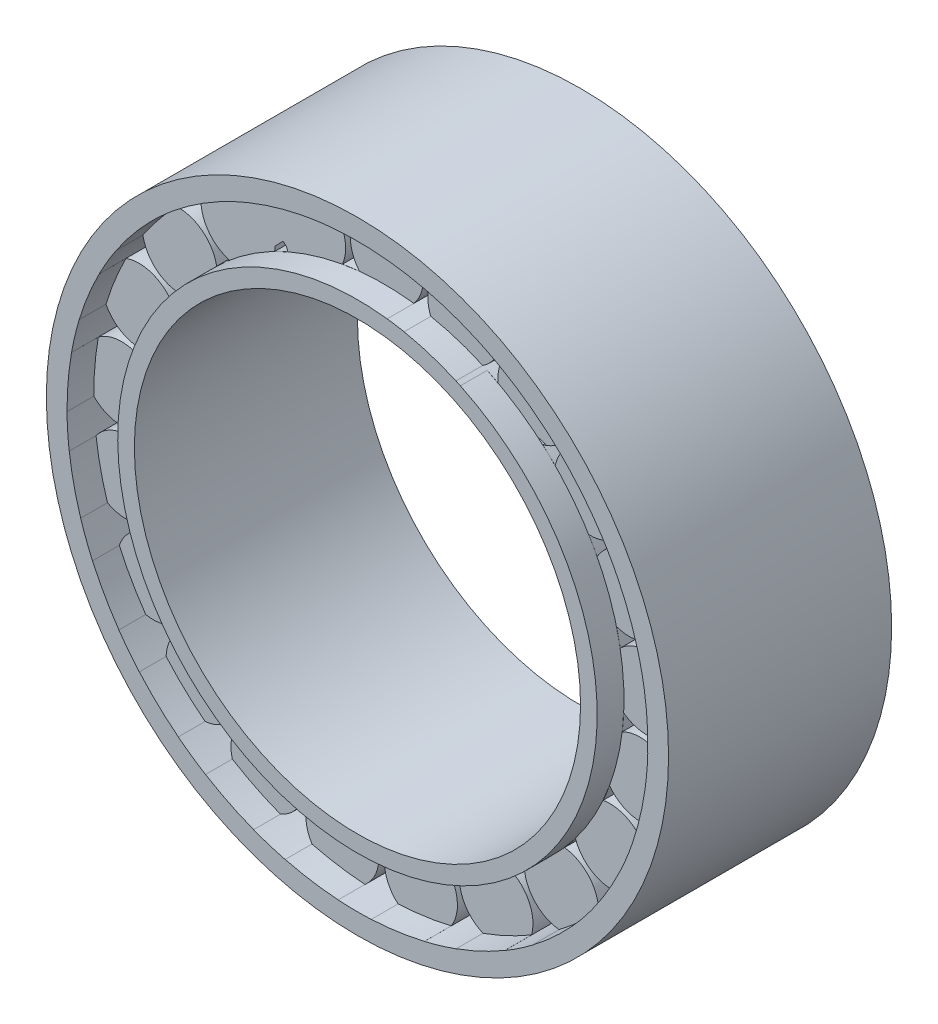
from build123d import *

# Parameters (mm, degrees)
SKETCH1_R          = 17.710128009
SKETCH1_R_2        = 12.7
BASE_EXTRUDE_DEPTH = 6.35
SKETCH2_R          = 16.531523604
SKETCH2_R_2        = 13.647455649
CUT_EXTRUDE1_DEPTH = 1.524


with BuildPart() as part:
    # Sketch1 → Base-Extrude (new body)
    with BuildSketch(Plane.XY):
        Circle(SKETCH1_R)
        Circle(SKETCH1_R_2, mode=Mode.SUBTRACT)
        with BuildLine():
            ThreePointArc((1.68979489, 13.542358951), (2.222472628, 14.997030336), (1.675382152, 16.446342732))
            ThreePointArc((1.675382152, 16.446342732), (2.615425849, 16.323254646), (3.546867553, 16.146480272))
            ThreePointArc((3.546867553, 16.146480272), (2.588094608, 14.932448412), (2.653777562, 13.386872576))
            ThreePointArc((2.653777562, 13.386872576), (2.173177263, 13.473239896), (1.68979489, 13.542358951))
        make_face(mode=Mode.SUBTRACT)
        with BuildLine():
            ThreePointArc((5.60700736, 12.442433831), (6.544791638, 13.675468729), (6.449199185, 15.22164999))
            ThreePointArc((6.449199185, 15.22164999), (7.311198528, 14.826947619), (8.149153729, 14.383479572))
            ThreePointArc((8.149153729, 14.383479572), (6.875134203, 13.505987029), (6.482332573, 12.0097164))
            ThreePointArc((6.482332573, 12.0097164), (6.048541211, 12.233906087), (5.60700736, 12.442433831))
        make_face(mode=Mode.SUBTRACT)
        with BuildLine():
            ThreePointArc((9.02598045, 10.236756654), (10.28554502, 11.138594502), (10.649944399, 12.644259638))
            ThreePointArc((10.649944399, 12.644259638), (11.357306963, 12.01301402), (12.027319665, 11.342256382))
            ThreePointArc((12.027319665, 11.342256382), (10.551255784, 10.879272218), (9.734871718, 9.565257008))
            ThreePointArc((9.734871718, 9.565257008), (9.386433559, 9.907348825), (9.02598045, 10.236756654))
        make_face(mode=Mode.SUBTRACT)
        with BuildLine():
            ThreePointArc((11.642923398, 7.121311516), (13.11235042, 7.611820064), (13.904363147, 8.94318412))
            ThreePointArc((13.904363147, 8.94318412), (14.394236664, 8.131484197), (14.836773297, 7.293036729))
            ThreePointArc((14.836773297, 7.293036729), (13.289819815, 7.285699119), (12.12239262, 6.270695346))
            ThreePointArc((12.12239262, 6.270695346), (11.890267925, 6.700292933), (11.642923398, 7.121311516))
        make_face(mode=Mode.SUBTRACT)
        with BuildLine():
            ThreePointArc((13.225309338, 3.372919389), (14.774033773, 3.4085148), (15.923286041, 4.447280237))
            ThreePointArc((15.923286041, 4.447280237), (16.1521431, 3.52724911), (16.327882343, 2.595611549))
            ThreePointArc((16.327882343, 2.595611549), (14.847492865, 3.044572471), (13.43275357, 2.418767674))
            ThreePointArc((13.43275357, 2.418767674), (13.337567635, 2.897699401), (13.225309338, 3.372919389))
        make_face(mode=Mode.SUBTRACT)
        with BuildLine():
            ThreePointArc((13.632536335, -0.675358637), (15.122947221, -1.097839171), (16.527322923, -0.44397122))
            ThreePointArc((16.527322923, -0.44397122), (16.47482857, -1.390584748), (16.368155218, -2.332632318))
            ThreePointArc((16.368155218, -2.332632318), (15.085868846, -1.467265011), (13.549523247, -1.648265329))
            ThreePointArc((13.549523247, -1.648265329), (13.599733761, -1.162554648), (13.632536335, -0.675358637))
        make_face(mode=Mode.SUBTRACT)
        with BuildLine():
            ThreePointArc((12.828420484, -4.663815293), (14.128088272, -5.506832523), (15.662802464, -5.295961096))
            ThreePointArc((15.662802464, -5.295961096), (15.333621052, -6.185046258), (14.954013503, -7.053798776))
            ThreePointArc((14.954013503, -7.053798776), (13.983767008, -5.848916767), (12.462326153, -5.569029934))
            ThreePointArc((12.462326153, -5.569029934), (12.653471691, -5.119697824), (12.828420484, -4.663815293))
        make_face(mode=Mode.SUBTRACT)
        with BuildLine():
            ThreePointArc((10.884411006, -8.238058703), (11.877854511, -9.426706849), (13.406541102, -9.677568797))
            ThreePointArc((13.406541102, -9.677568797), (12.829921844, -10.430126475), (12.211109893, -11.148391466))
            ThreePointArc((12.211109893, -11.148391466), (11.639113935, -9.71105381), (10.26776452, -8.995148999))
            ThreePointArc((10.26776452, -8.995148999), (10.582860963, -8.62212059), (10.884411006, -8.238058703))
        make_face(mode=Mode.SUBTRACT)
        with BuildLine():
            ThreePointArc((7.973241676, -11.080501654), (8.572189081, -12.509164111), (9.959017559, -13.199469249))
            ThreePointArc((9.959017559, -13.199469249), (9.186195607, -13.748631392), (8.383163412, -14.252587861))
            ThreePointArc((8.383163412, -14.252587861), (8.260242341, -12.710508315), (7.160834781, -11.62219681))
            ThreePointArc((7.160834781, -11.62219681), (7.571884426, -11.358617314), (7.973241676, -11.080501654))
        make_face(mode=Mode.SUBTRACT)
        with BuildLine():
            ThreePointArc((4.353582662, -12.938580617), (4.504814864, -14.480314456), (5.626559432, -15.548726144))
            ThreePointArc((5.626559432, -15.548726144), (4.726203408, -15.845697284), (3.810303904, -16.090566486))
            ThreePointArc((3.810303904, -16.090566486), (4.147379796, -14.580765586), (3.417601276, -13.21674864))
            ThreePointArc((3.417601276, -13.21674864), (3.88808056, -13.086038252), (4.353582662, -12.938580617))
        make_face(mode=Mode.SUBTRACT)
        with BuildLine():
            ThreePointArc((0.347056555, -13.64719712), (0.037135907, -15.165012525), (0.794124638, -16.516597695))
            ThreePointArc((0.794124638, -16.516597695), (-0.153764874, -16.534990644), (-1.101149998, -16.499014876))
            ThreePointArc((-1.101149998, -16.499014876), (-0.334027814, -15.155645057), (-0.629333269, -13.637121562))
            ThreePointArc((-0.629333269, -13.637121562), (-0.141228497, -13.650894473), (0.347056555, -13.64719712))
        make_face(mode=Mode.SUBTRACT)
        with BuildLine():
            ThreePointArc((-3.690339221, -13.143387479), (-4.433874908, -14.50241989), (-4.108903785, -16.017084268))
            ThreePointArc((-4.108903785, -16.017084268), (-5.020102642, -15.755264732), (-5.914794059, -15.441640599))
            ThreePointArc((-5.914794059, -15.441640599), (-4.785787756, -14.384066165), (-4.620380961, -12.845963597))
            ThreePointArc((-4.620380961, -12.845963597), (-4.158020951, -13.002996024), (-3.690339221, -13.143387479))
        make_face(mode=Mode.SUBTRACT)
        with BuildLine():
            ThreePointArc((-7.399864331, -11.471917391), (-8.510948649, -12.551410813), (-8.646870244, -14.094569823))
            ThreePointArc((-8.646870244, -14.094569823), (-9.44041443, -13.575801616), (-10.202914882, -13.012395999))
            ThreePointArc((-10.202914882, -13.012395999), (-8.812341624, -12.334587079), (-8.200919698, -10.913572602))
            ThreePointArc((-8.200919698, -10.913572602), (-7.805387166, -11.199911524), (-7.399864331, -11.471917391))
        make_face(mode=Mode.SUBTRACT)
        with BuildLine():
            ThreePointArc((-10.451911192, -8.781304308), (-11.831819423, -9.485341015), (-12.416556506, -10.919878206))
            ThreePointArc((-12.416556506, -10.919878206), (-13.021936137, -10.19025616), (-13.584494112, -9.42713012))
            ThreePointArc((-13.584494112, -9.42713012), (-12.055912436, -9.189313012), (-11.052802901, -8.011649997))
            ThreePointArc((-11.052802901, -8.011649997), (-10.759242648, -8.401852944), (-10.451911192, -8.781304308))
        make_face(mode=Mode.SUBTRACT)
        with BuildLine():
            ThreePointArc((-12.575292045, -5.310621011), (-14.101413288, -5.57664425), (-15.083009403, -6.775094698))
            ThreePointArc((-15.083009403, -6.775094698), (-15.446433842, -5.899448934), (-15.759063595, -5.004409569))
            ThreePointArc((-15.759063595, -5.004409569), (-14.228294691, -5.227715366), (-12.922628231, -4.398044341))
            ThreePointArc((-12.922628231, -4.398044341), (-12.757124375, -4.857440069), (-12.575292045, -5.310621011))
        make_face(mode=Mode.SUBTRACT)
        with BuildLine():
            ThreePointArc((-13.581335184, -1.36825294), (-15.118066868, -1.172625381), (-16.409302893, -2.028501504))
            ThreePointArc((-16.409302893, -2.028501504), (-16.498480284, -1.08463699), (-16.53340329, -0.137212475))
            ThreePointArc((-16.53340329, -0.137212475), (-15.136462693, -0.801799477), (-13.644253502, -0.393840353))
            ThreePointArc((-13.644253502, -0.393840353), (-13.621511786, -0.881609536), (-13.581335184, -1.36825294))
        make_face(mode=Mode.SUBTRACT)
        with BuildLine():
            ThreePointArc((-13.380649262, 2.695503199), (-14.791446033, 3.335399191), (-16.27758998, 2.898145742))
            ThreePointArc((-16.27758998, 2.898145742), (-16.08459652, 3.826362501), (-15.838709717, 4.74198934))
            ThreePointArc((-15.838709717, 4.74198934), (-14.699721729, 3.695172604), (-13.153559143, 3.645170869))
            ThreePointArc((-13.153559143, 3.645170869), (-13.275600268, 3.172368663), (-13.380649262, 2.695503199))
        make_face(mode=Mode.SUBTRACT)
        with BuildLine():
            ThreePointArc((-11.991066101, 6.519564841), (-13.150572476, 7.546871698), (-14.699573934, 7.567092811))
            ThreePointArc((-14.699573934, 7.567092811), (-14.241557939, 8.397185683), (-13.736709448, 9.199657384))
            ThreePointArc((-13.736709448, 9.199657384), (-12.956878151, 7.863625175), (-11.4941455, 7.360105453))
            ThreePointArc((-11.4941455, 7.360105453), (-11.750125577, 6.944280776), (-11.991066101, 6.519564841))
        make_face(mode=Mode.SUBTRACT)
        with BuildLine():
            ThreePointArc((-9.536056266, 9.764147328), (-10.341245014, 11.087584326), (-11.815468406, 11.563483267))
            ThreePointArc((-11.815468406, 11.563483267), (-11.133126607, 12.221694858), (-10.414174432, 12.839708287))
            ThreePointArc((-10.414174432, 12.839708287), (-10.062791258, 11.33317293), (-8.813458758, 10.42087516))
            ThreePointArc((-8.813458758, 10.42087516), (-9.180632834, 10.098975859), (-9.536056266, 9.764147328))
        make_face(mode=Mode.SUBTRACT)
        with BuildLine():
            ThreePointArc((-6.233758153, 12.140955265), (-6.613084721, 13.642929221), (-7.881538828, 14.532220281))
            ThreePointArc((-7.881538828, 14.532220281), (-7.035500289, 14.960065601), (-6.166326486, 15.338707554))
            ThreePointArc((-6.166326486, 15.338707554), (-6.274613371, 13.795531327), (-5.349689698, 12.555517168))
            ThreePointArc((-5.349689698, 12.555517168), (-5.795432744, 12.356145409), (-6.233758153, 12.140955265))
        make_face(mode=Mode.SUBTRACT)
        with BuildLine():
            ThreePointArc((-2.377595441, 13.438798839), (-2.297354998, 14.985852775), (-3.247332107, 16.209518539))
            ThreePointArc((-3.247332107, 16.209518539), (-2.312771064, 16.368981655), (-1.37060554, 16.474608132))
            ThreePointArc((-1.37060554, 16.474608132), (-1.928940721, 15.031909016), (-1.410609401, 13.574359168))
            ThreePointArc((-1.410609401, 13.574359168), (-1.895315192, 13.515230005), (-2.377595441, 13.438798839))
        make_face(mode=Mode.SUBTRACT)
    extrude(amount=-BASE_EXTRUDE_DEPTH)

    # Sketch2 → Cut-Extrude1 (cut)
    with BuildSketch(Plane.XY):
        Circle(SKETCH2_R)
        Circle(SKETCH2_R_2, mode=Mode.SUBTRACT)
    extrude(amount=-CUT_EXTRUDE1_DEPTH, mode=Mode.SUBTRACT)

    # Mirror All1: part across plane


with BuildPart() as part_1:
    add(part.part)
    add(part.part.mirror(Plane.XY.offset(-6.35)))


solid = part_1.part
